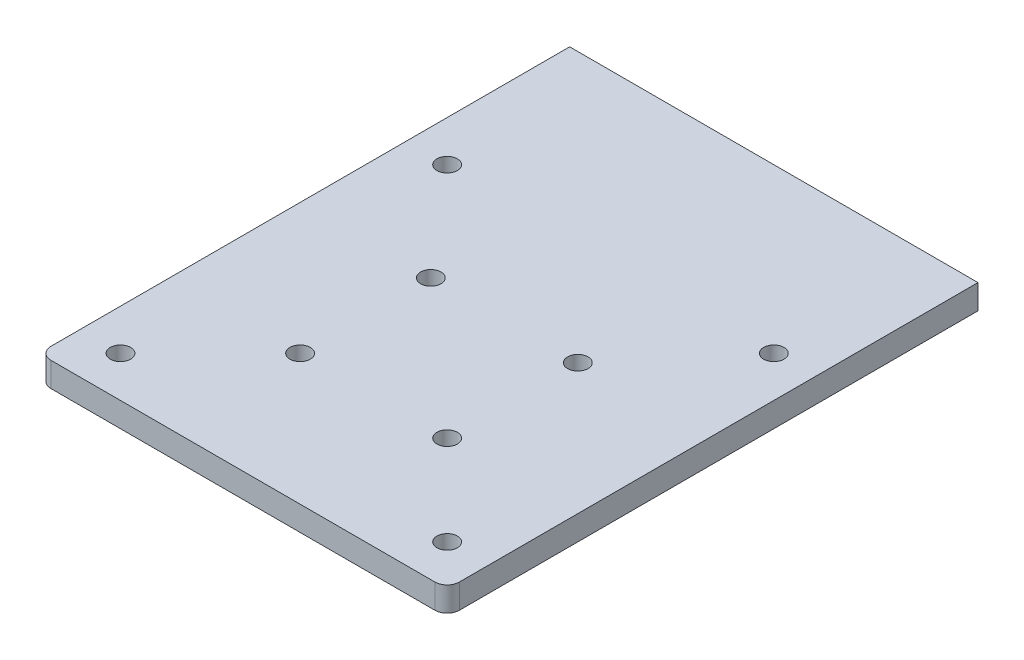
from build123d import *

# Parameters (mm, degrees)
SKETCH1_W           = 100
SKETCH1_H           = 130
SKETCH1_R           = 2.5
BOSS_EXTRUDE1_DEPTH = 6
FILLET1_R           = 3
SCALE1_SCALE        = 7.5


with BuildPart() as part:
    # Sketch1 → Boss-Extrude1 (new body)
    with BuildSketch(Plane(origin=(0, 0, 0), x_dir=(1, 0, 0), z_dir=(0, 1, 0))):
        with Locations((40, 55)):
            Rectangle(SKETCH1_W, SKETCH1_H)
        Circle(SKETCH1_R, mode=Mode.SUBTRACT)
        with Locations((80, 0)):
            Circle(SKETCH1_R, mode=Mode.SUBTRACT)
        with Locations((0, 80)):
            Circle(SKETCH1_R, mode=Mode.SUBTRACT)
        with Locations((80, 80)):
            Circle(SKETCH1_R, mode=Mode.SUBTRACT)
        with Locations((22, 22)):
            Circle(SKETCH1_R, mode=Mode.SUBTRACT)
        with Locations((58, 22)):
            Circle(SKETCH1_R, mode=Mode.SUBTRACT)
        with Locations((22, 54)):
            Circle(SKETCH1_R, mode=Mode.SUBTRACT)
        with Locations((58, 54)):
            Circle(SKETCH1_R, mode=Mode.SUBTRACT)
    extrude(amount=BOSS_EXTRUDE1_DEPTH)

    # Fillet1
    fillet1_edges = [part.edges().sort_by_distance(p)[0] for p in [
        (90, 3, 10),
        (-10, 3, 10),
    ]]
    fillet(fillet1_edges, radius=FILLET1_R)


with BuildPart() as part_1:
    # Scale1: scaled about (40, 3, -55.215106893)
    add(part.part.scale(SCALE1_SCALE).moved(Location((-260, -19.5, 358.898194805))))


solid = part_1.part
